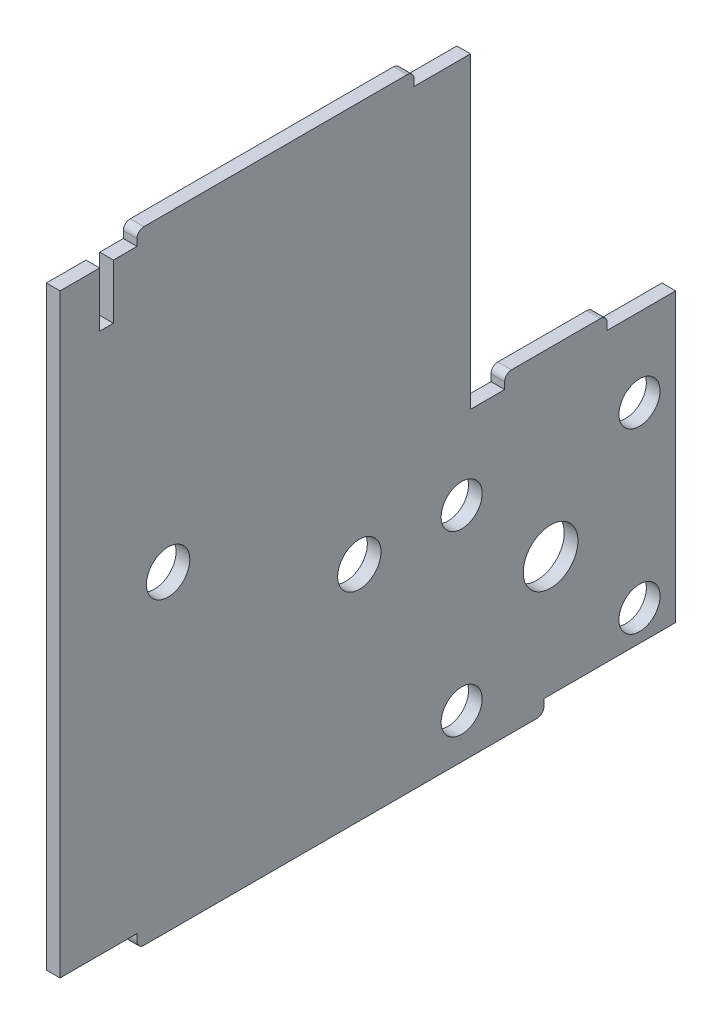
from build123d import *

# Parameters (mm, degrees)
SKETCH1_R           = 4
SKETCH1_R_2         = 3
SKETCH1_R_3         = 3.17
BOSS_EXTRUDE1_DEPTH = 2


with BuildPart() as part:
    # Sketch1 → Boss-Extrude1 (new body)
    with BuildSketch(Plane(origin=(0, 0, 0), x_dir=(0, 0, -1), z_dir=(1, 0, 0))):
        with BuildLine():
            Line((22.098803657, -49.511248032), (22.098803657, -7.511248032))
            Line((22.098803657, -7.511248032), (12.098803657, -7.511248032))
            Line((12.098803657, -7.511248032), (12.098803657, -6.511248032))
            ThreePointArc((12.098803657, -6.511248032), (11.805910438, -5.804141251), (11.098803657, -5.511248032))
            Line((11.098803657, -5.511248032), (-1.901196343, -5.511248032))
            ThreePointArc((-1.901196343, -5.511248032), (-2.608303125, -5.804141251), (-2.901196343, -6.511248032))
            Line((-2.901196343, -6.511248032), (-2.901196343, -7.511248032))
            Line((-2.901196343, -7.511248032), (-7.901196343, -7.511248032))
            Line((-7.901196343, -7.511248032), (-7.901196343, 37.488751968))
            Line((-7.901196343, 37.488751968), (-16.151705215, 37.488751968))
            Line((-16.151705215, 37.488751968), (-16.151705215, 38.488751968))
            ThreePointArc((-16.151705215, 38.488751968), (-16.444598434, 39.195858749), (-17.151705215, 39.488751968))
            Line((-17.151705215, 39.488751968), (-55.650687472, 39.488751968))
            ThreePointArc((-55.650687472, 39.488751968), (-56.357794253, 39.195858749), (-56.650687472, 38.488751968))
            Line((-56.650687472, 38.488751968), (-56.650687472, 37.488751968))
            Line((-56.650687472, 37.488751968), (-60.101196343, 37.488751968))
            Line((-60.101196343, 37.488751968), (-60.101196343, 29.488751968))
            Line((-60.101196343, 29.488751968), (-62.101196343, 29.488751968))
            Line((-62.101196343, 29.488751968), (-62.101196343, 37.488751968))
            Line((-62.101196343, 37.488751968), (-67.901196343, 37.488751968))
            Line((-67.901196343, 37.488751968), (-67.901196343, -49.511248032))
            Line((-67.901196343, -49.511248032), (-56.650687472, -49.511248032))
            Line((-56.650687472, -49.511248032), (-56.650687472, -50.511248032))
            ThreePointArc((-56.650687472, -50.511248032), (-56.357794253, -51.218354813), (-55.650687472, -51.511248032))
            Line((-55.650687472, -51.511248032), (1.848294785, -51.511248032))
            ThreePointArc((1.848294785, -51.511248032), (2.555401566, -51.218354813), (2.848294785, -50.511248032))
            Line((2.848294785, -50.511248032), (2.848294785, -49.511248032))
            Line((2.848294785, -49.511248032), (22.098803657, -49.511248032))
        make_face()
        with Locations((3.81328303, -32.011248032)):
            Circle(SKETCH1_R, mode=Mode.SUBTRACT)
        with Locations((-9.18671697, -19.011248032)):
            Circle(SKETCH1_R_2, mode=Mode.SUBTRACT)
        with Locations((16.81328303, -19.011248032)):
            Circle(SKETCH1_R_2, mode=Mode.SUBTRACT)
        with Locations((16.81328303, -45.011248032)):
            Circle(SKETCH1_R_2, mode=Mode.SUBTRACT)
        with Locations((-9.18671697, -45.011248032)):
            Circle(SKETCH1_R_2, mode=Mode.SUBTRACT)
        with Locations((-52.101196343, -6.011248032)):
            Circle(SKETCH1_R_3, mode=Mode.SUBTRACT)
        with Locations((-24.143956657, -19.011248032)):
            Circle(SKETCH1_R_3, mode=Mode.SUBTRACT)
    extrude(amount=BOSS_EXTRUDE1_DEPTH)


solid = part.part
